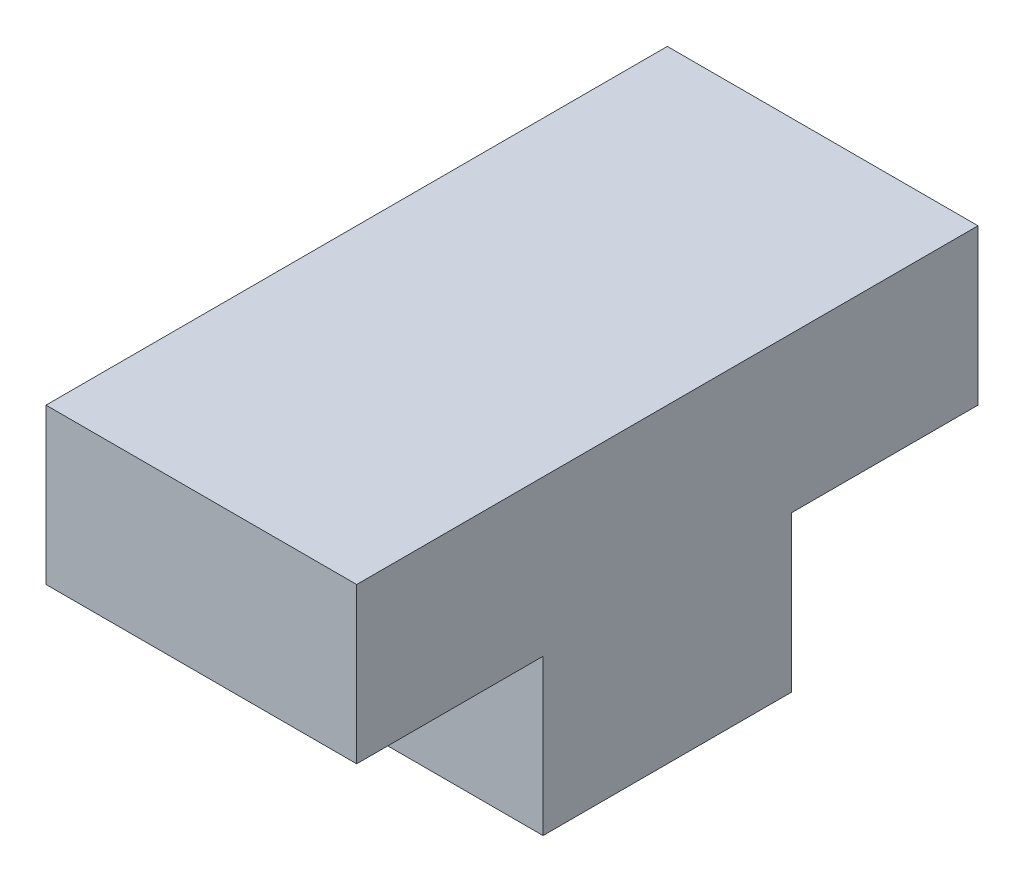
from build123d import *

# Parameters (mm, degrees)
BOSS_EXTRUDE1_DEPTH = 10


with BuildPart() as part:
    # Sketch1 → Boss-Extrude1 (new body)
    with BuildSketch(Plane(origin=(0, 0, 0), x_dir=(0, 0, -1), z_dir=(1, 0, 0))):
        Polygon((-4, 0), (4, 0), (4, 5), (10, 5), (10, 10), (-10, 10), (-10, 5), (-4, 5), align=None)
    extrude(amount=BOSS_EXTRUDE1_DEPTH)


solid = part.part
